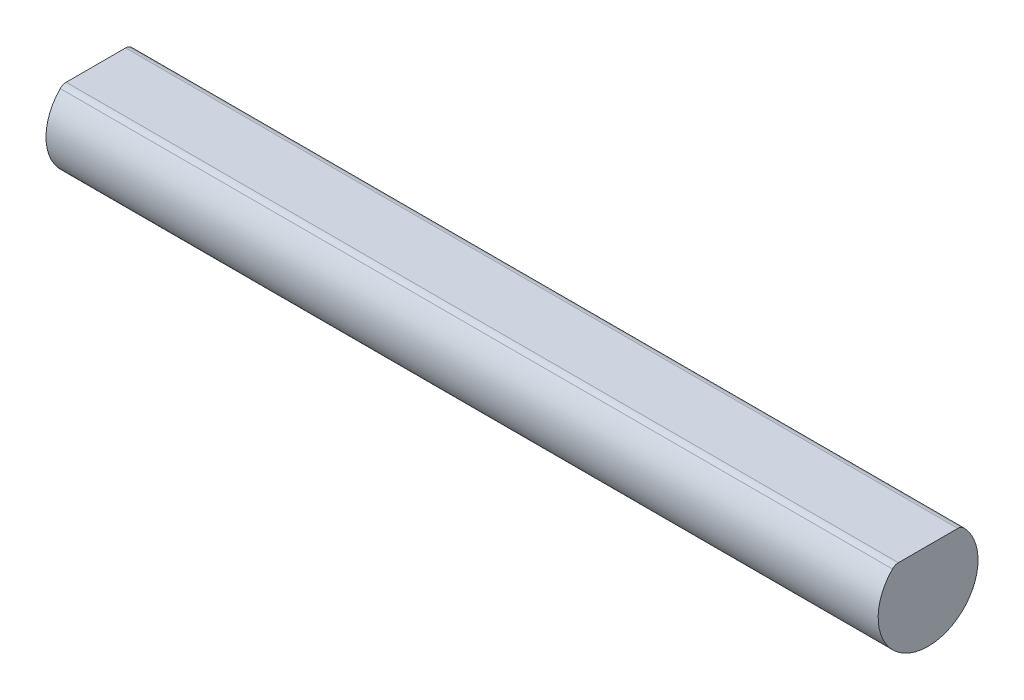
from build123d import *

# Parameters (mm, degrees)
SKETCH1_R           = 6
BOSS_EXTRUDE1_DEPTH = 100
CUT_EXTRUDE1_DEPTH  = 101
FILLET1_R           = 1


with BuildPart() as part:
    # Sketch1 → Boss-Extrude1 (new body)
    with BuildSketch(Plane(origin=(0, 0, 0), x_dir=(0, 0, -1), z_dir=(1, 0, 0))):
        Circle(SKETCH1_R)
    extrude(amount=BOSS_EXTRUDE1_DEPTH)

    # Sketch2 → Cut-Extrude1 (cut, through all)
    with BuildSketch(Plane(origin=(100, 0, 0), x_dir=(0, 0, -1), z_dir=(1, 0, 0))):
        Polygon((45.463107393, 6.099427515), (3.968626967, 6.099427515), (-3.968626967, 6.099427515), (-3.968626967, 4.5), (3.968626967, 4.5), (3.968626967, 6.19024408), (3.968626967, 47.684724507), (-54.777541729, -10.933150643), (-13.283061303, -52.518447634), align=None)
    extrude(amount=-CUT_EXTRUDE1_DEPTH, mode=Mode.SUBTRACT)

    # Fillet1
    fillet1_edges = [part.edges().sort_by_distance(p)[0] for p in [
        (50, 4.5, 3.968626967),
        (50, 4.5, -3.968626967),
    ]]
    fillet(fillet1_edges, radius=FILLET1_R)


solid = part.part
